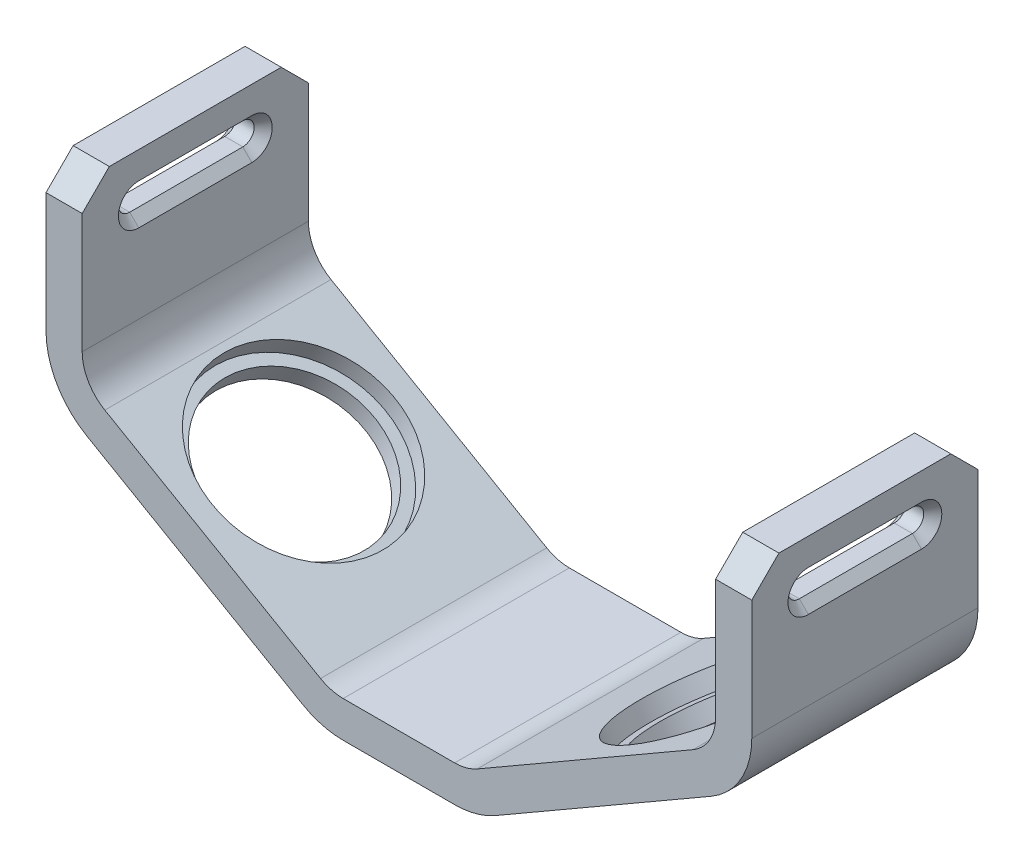
from build123d import *

# Parameters (mm, degrees)
BOSS_EXTRUDE1_DEPTH      = 50
FILLET1_R                = 10
FILLET2_R                = 18
CUT_EXTRUDE1_DEPTH       = 8
CHAMFER1_SIZE            = 2
CHAMFER2_SIZE            = 6
SKETCH3_R                = 17.75
CUT_EXTRUDE2_DEPTH       = 8
SKETCH4_R                = 20.25
CUT_EXTRUDE3_DEPTH       = 4
CHAMFER1_OF_MIRROR2_SIZE = 2
CHAMFER2_OF_MIRROR2_SIZE = 6


with BuildPart() as part:
    # Sketch1 → Boss-Extrude1 (new body)
    with BuildSketch(Plane.XY):
        Polygon((-15, 0), (15, 0), (70, 31.754264805), (70, 70), (78, 70), (78, 27.135462652), (17.143593539, -8), (-17.143593539, -8), (-78, 27.135462652), (-78, 70), (-70, 70), (-70, 31.754264805), align=None)
    extrude(amount=BOSS_EXTRUDE1_DEPTH)

    # Fillet1
    fillet1_edges = [part.edges().sort_by_distance(p)[0] for p in [
        (-15, 0, 25),
        (15, 0, 25),
        (70, 31.754264805, 25),
        (-70, 31.754264805, 25),
    ]]
    fillet(fillet1_edges, radius=FILLET1_R)

    # Fillet2
    fillet2_edges = [part.edges().sort_by_distance(p)[0] for p in [
        (78, 27.135462652, 25),
        (17.143593539, -8, 25),
        (-17.143593539, -8, 25),
        (-78, 27.135462652, 25),
    ]]
    fillet(fillet2_edges, radius=FILLET2_R)

    # Sketch2 → Cut-Extrude1 (cut)
    with BuildSketch(Plane(origin=(-78, 160.753072215, 0), x_dir=(0, 0, 1), z_dir=(1, 0, 0))):
        with BuildLine():
            Line((12.5, 103.753072215), (37.5, 103.753072215))
            ThreePointArc((37.5, 103.753072215), (40, 101.253072215), (37.5, 98.753072215))
            Line((37.5, 98.753072215), (12.5, 98.753072215))
            ThreePointArc((12.5, 98.753072215), (10, 101.253072215), (12.5, 103.753072215))
        make_face()
    cut_extrude1 = extrude(amount=CUT_EXTRUDE1_DEPTH, mode=Mode.SUBTRACT)

    # Chamfer1
    chamfer1_edges = [part.edges().sort_by_distance(p)[0] for p in [
        (-70, 59.5, 10),
        (-78, 59.5, 10),
        (-70, 62, 25),
        (-78, 62, 25),
        (-70, 59.5, 40),
        (-78, 59.5, 40),
        (-70, 57, 25),
        (-78, 57, 25),
    ]]
    chamfer(chamfer1_edges, length=CHAMFER1_SIZE)

    # Chamfer2
    chamfer2_edges = [part.edges().sort_by_distance(p)[0] for p in [
        (-74, 70, 50),
        (-74, 70, 0),
    ]]
    chamfer(chamfer2_edges, length=CHAMFER2_SIZE)

    # Sketch3 → Cut-Extrude2 (cut)
    with BuildSketch(Plane(origin=(-27.350055988, -2.107296158, 0), x_dir=(0, 0, 1), z_dir=(0.5, 0.866025404, 0))):
        with Locations(Location((25, -26.237677779, 0), (0, 0, 90))):  # turned: the seam where the file's is
            Circle(SKETCH3_R)
    cut_extrude2 = extrude(amount=CUT_EXTRUDE2_DEPTH, mode=Mode.SUBTRACT)

    # Sketch4 → Cut-Extrude3 (cut)
    with BuildSketch(Plane(origin=(-3.75, -6.495190528, 0), x_dir=(0, 0, -1), z_dir=(0.5, 0.866025404, 0))):
        with Locations(Location((-25, 48.869872981, 0), (0, 0, 90))):  # turned: the seam where the file's is
            Circle(SKETCH4_R)
    cut_extrude3 = extrude(amount=-CUT_EXTRUDE3_DEPTH, mode=Mode.SUBTRACT)

    # Mirror2: Cut-Extrude1, Cut-Extrude2, Cut-Extrude3 across plane
    add(cut_extrude1.mirror(Plane(origin=(0, 0, 0), x_dir=(0, 0, 1), z_dir=(1, 0, 0))), mode=Mode.SUBTRACT)
    add(cut_extrude2.mirror(Plane(origin=(0, 0, 0), x_dir=(0, 0, 1), z_dir=(1, 0, 0))), mode=Mode.SUBTRACT)
    add(cut_extrude3.mirror(Plane(origin=(0, 0, 0), x_dir=(0, 0, 1), z_dir=(1, 0, 0))), mode=Mode.SUBTRACT)

    # Chamfer1 of Mirror2
    chamfer1_of_mirror2_edges = [part.edges().sort_by_distance(p)[0] for p in [
        (70, 59.5, 10),
        (78, 59.5, 10),
        (70, 62, 25),
        (78, 62, 25),
        (70, 59.5, 40),
        (78, 59.5, 40),
        (70, 57, 25),
        (78, 57, 25),
    ]]
    chamfer(chamfer1_of_mirror2_edges, length=CHAMFER1_OF_MIRROR2_SIZE)

    # Chamfer2 of Mirror2
    chamfer2_of_mirror2_edges = [part.edges().sort_by_distance(p)[0] for p in [
        (74, 70, 50),
        (74, 70, 0),
    ]]
    chamfer(chamfer2_of_mirror2_edges, length=CHAMFER2_OF_MIRROR2_SIZE)


solid = part.part
